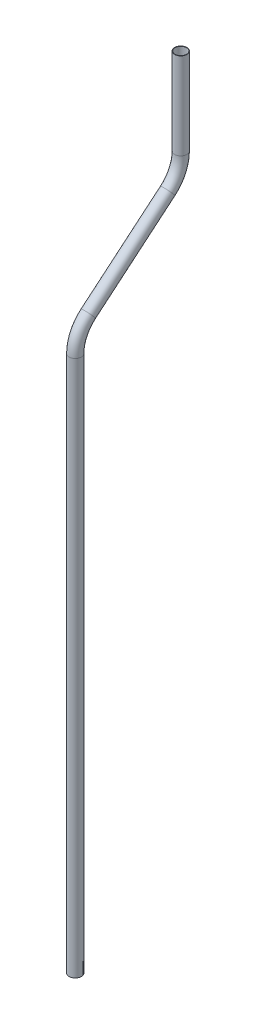
from build123d import *

# Parameters (mm, degrees)
SKETCH1_R   = 6.35
SKETCH1_R_2 = 5.969


with BuildPart() as part:
    # Sweep2: sweep along a path in Sketch2
    with BuildLine(Plane(origin=(0, 0, 0), x_dir=(0, 0, -1), z_dir=(1, 0, 0))) as sweep2_path:
        Line((0, 0), (0, 558.8))
        ThreePointArc((0, 558.8), (3.569673314, 574.901755772), (13.609792071, 587.986293283))
        Line((13.609792071, 587.986293283), (96.304289706, 657.375215748))
        ThreePointArc((96.304289706, 657.375215748), (106.344408463, 670.459753259), (109.914081777, 686.561509031))
        Line((109.914081777, 686.561509031), (109.914081777, 776.731509031))
    # Sketch1 → Sweep2 (sweep)
    with BuildSketch(Plane(origin=(0, 0, 0), x_dir=(1, 0, 0), z_dir=(0, 1, 0))):
        Circle(SKETCH1_R)
        Circle(SKETCH1_R_2, mode=Mode.SUBTRACT)
    sweep(path=sweep2_path.line)


solid = part.part
